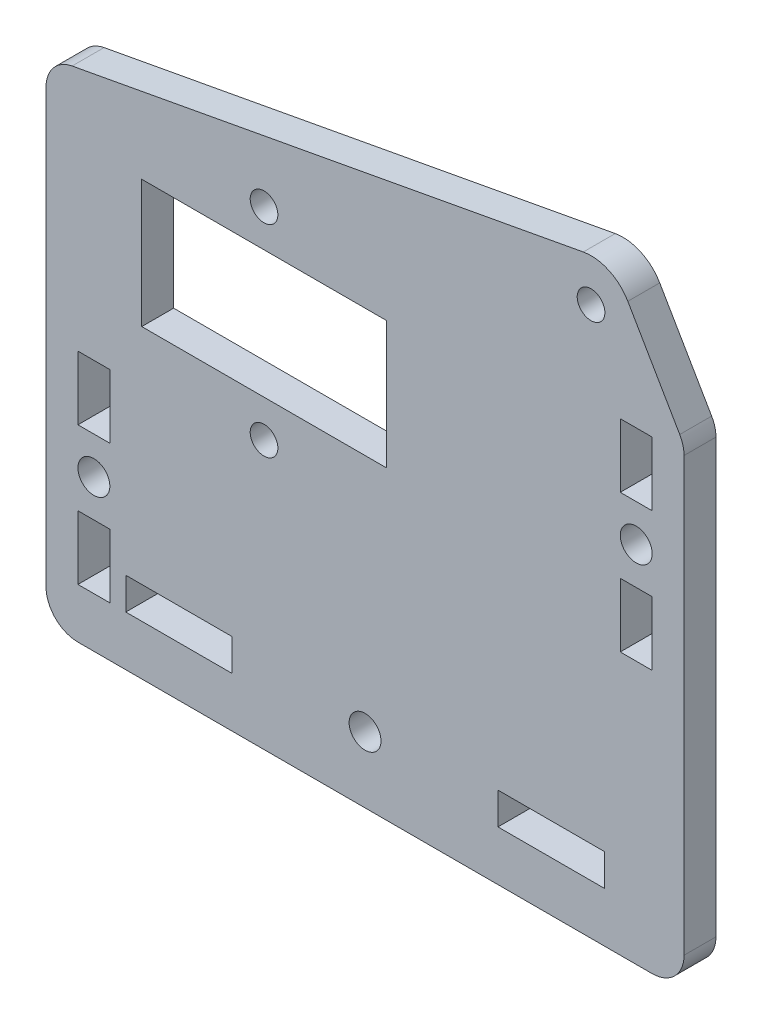
from build123d import *

# Parameters (mm, degrees)
MODEL_R             = 1.300000008
MODEL_R_2           = 1.3
MODEL_R_3           = 1.500000002
MODEL_W             = 3
MODEL_H             = 6
MODEL_W_2           = 23
MODEL_H_2           = 12
MODEL_W_3           = 10
MODEL_H_3           = 3
BOSS_EXTRUDE1_DEPTH = 3


with BuildPart() as part:
    # Model → Boss-Extrude1 (new body)
    with BuildSketch(Plane.XY):
        with BuildLine():
            Line((24.95163, 51.857462577), (24.95163, 11.157702759))
            ThreePointArc((24.95163, 11.157702759), (25.830365801, 9.036226784), (27.95183001, 8.157462577))
            Line((27.95183001, 8.157462577), (81.95183001, 8.157462577))
            ThreePointArc((81.95183001, 8.157462577), (84.0730792, 9.036166136), (84.951725641, 11.157438987))
            Line((84.951725641, 11.157438987), (84.95183, 51.857462577))
            ThreePointArc((84.95183, 51.857462577), (84.848554916, 52.637712888), (84.54593, 53.364262577))
            Line((84.54593, 53.364262577), (79.66303, 61.771262577))
            ThreePointArc((79.66303, 61.771262577), (77.874800295, 63.39663974), (75.47683, 63.695562577))
            Line((75.47683, 63.695562577), (27.40633, 54.807462577))
            ThreePointArc((27.40633, 54.807462577), (25.64557658, 53.776308467), (24.95163, 51.857462577))
        make_face()
        with Locations((45.451629992, 52.357462585)):
            Circle(MODEL_R, mode=Mode.SUBTRACT)
        with Locations((45.451829992, 33.357462569)):
            Circle(MODEL_R, mode=Mode.SUBTRACT)
        with Locations((76.20413, 59.762262577)):
            Circle(MODEL_R_2, mode=Mode.SUBTRACT)
        with Locations((54.951729998, 14.357462579)):
            Circle(MODEL_R_3, mode=Mode.SUBTRACT)
        with Locations((29.451829998, 22.357462575)):
            Circle(MODEL_R_3, mode=Mode.SUBTRACT)
        with Locations((80.451829998, 42.357462575)):
            Circle(MODEL_R_3, mode=Mode.SUBTRACT)
        with Locations((29.45183, 28.857462577)):
            Rectangle(MODEL_W, MODEL_H, mode=Mode.SUBTRACT)
        with Locations((45.45183, 42.857462577)):
            Rectangle(MODEL_W_2, MODEL_H_2, mode=Mode.SUBTRACT)
        with Locations((29.45183, 15.857462577)):
            Rectangle(MODEL_W, MODEL_H, mode=Mode.SUBTRACT)
        with Locations((37.45183, 14.357462577)):
            Rectangle(MODEL_W_3, MODEL_H_3, mode=Mode.SUBTRACT)
        with Locations((72.45183, 14.357462577)):
            Rectangle(MODEL_W_3, MODEL_H_3, mode=Mode.SUBTRACT)
        with Locations((80.45183, 35.857462577)):
            Rectangle(MODEL_W, MODEL_H, mode=Mode.SUBTRACT)
        with Locations((80.45183, 48.857462577)):
            Rectangle(MODEL_W, MODEL_H, mode=Mode.SUBTRACT)
    extrude(amount=BOSS_EXTRUDE1_DEPTH)


solid = part.part
